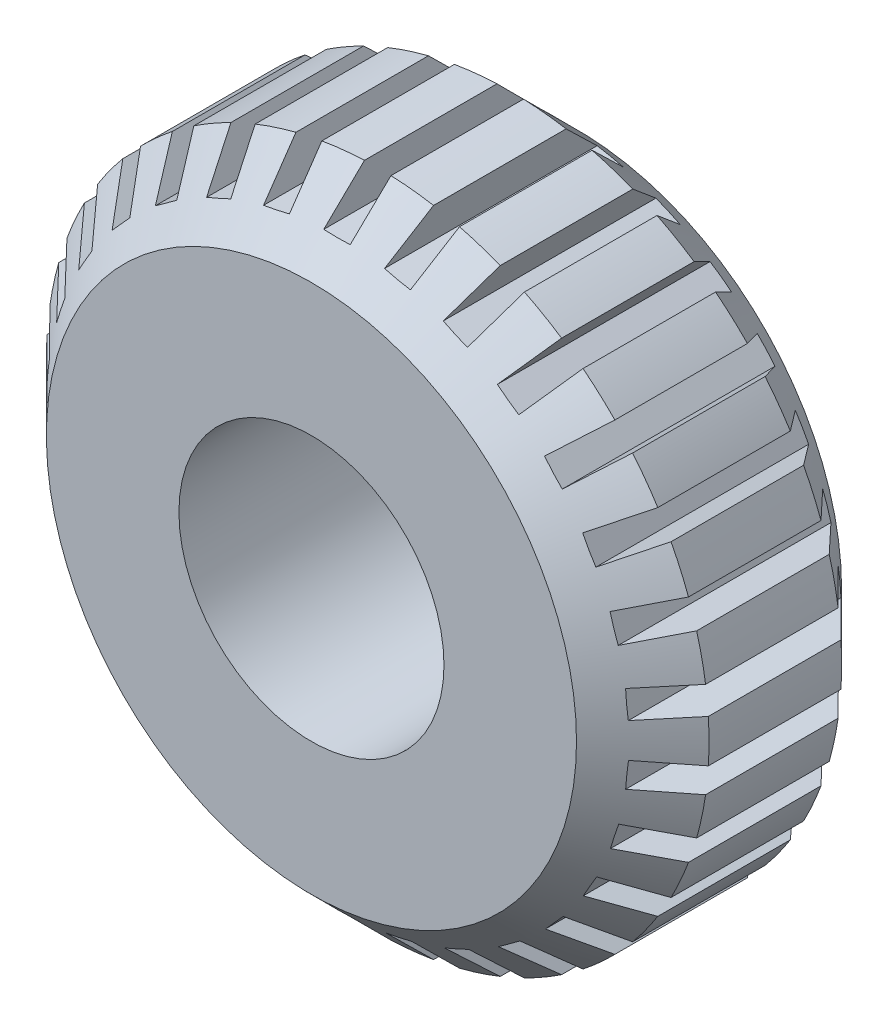
from build123d import *

# Parameters (mm, degrees)
SKETCH1_R           = 50
SKETCH1_R_2         = 20
BOSS_EXTRUDE6_DEPTH = 40
CHAMFER9_SIZE       = 10
CUT_EXTRUDE5_DEPTH  = 40
CIRPATTERN5_COUNT   = 30


with BuildPart() as part:
    # Sketch1 → Boss-Extrude6 (new body)
    with BuildSketch(Plane.XY):
        with Locations((0.830696971, 0)):
            Circle(SKETCH1_R)
        with Locations((0.830696971, 0)):
            Circle(SKETCH1_R_2, mode=Mode.SUBTRACT)
    extrude(amount=BOSS_EXTRUDE6_DEPTH)

    # Chamfer9
    chamfer9_edges = [part.edges().sort_by_distance(p)[0] for p in [
        (-49.169303029, 0, 0),
        (-49.169303029, 0, 40),
    ]]
    chamfer(chamfer9_edges, length=CHAMFER9_SIZE)

    # Sketch5 → Cut-Extrude5 (cut)
    with BuildSketch(Plane.XY):
        with BuildLine():
            Line((-1.270804069, 43.907222553), (2.729747939, 43.907222553))
            Line((2.729747939, 43.907222553), (2.830308409, 49.959999541))
            ThreePointArc((2.830308409, 49.959999541), (0.83003143, 49.999999996), (-1.170244483, 49.95994629))
            Line((-1.170244483, 49.95994629), (-1.270804069, 43.907222553))
        make_face()
    cut_extrude5 = extrude(amount=CUT_EXTRUDE5_DEPTH, mode=Mode.SUBTRACT)

    # CirPattern5: Cut-Extrude5 ×30 about axis
    cirpattern5_axis = Axis((0.830696971, 0, 0), (0, 0, 1))
    for i in range(1, CIRPATTERN5_COUNT):
        add(cut_extrude5.rotate(cirpattern5_axis, i * 360 / CIRPATTERN5_COUNT), mode=Mode.SUBTRACT)


solid = part.part
